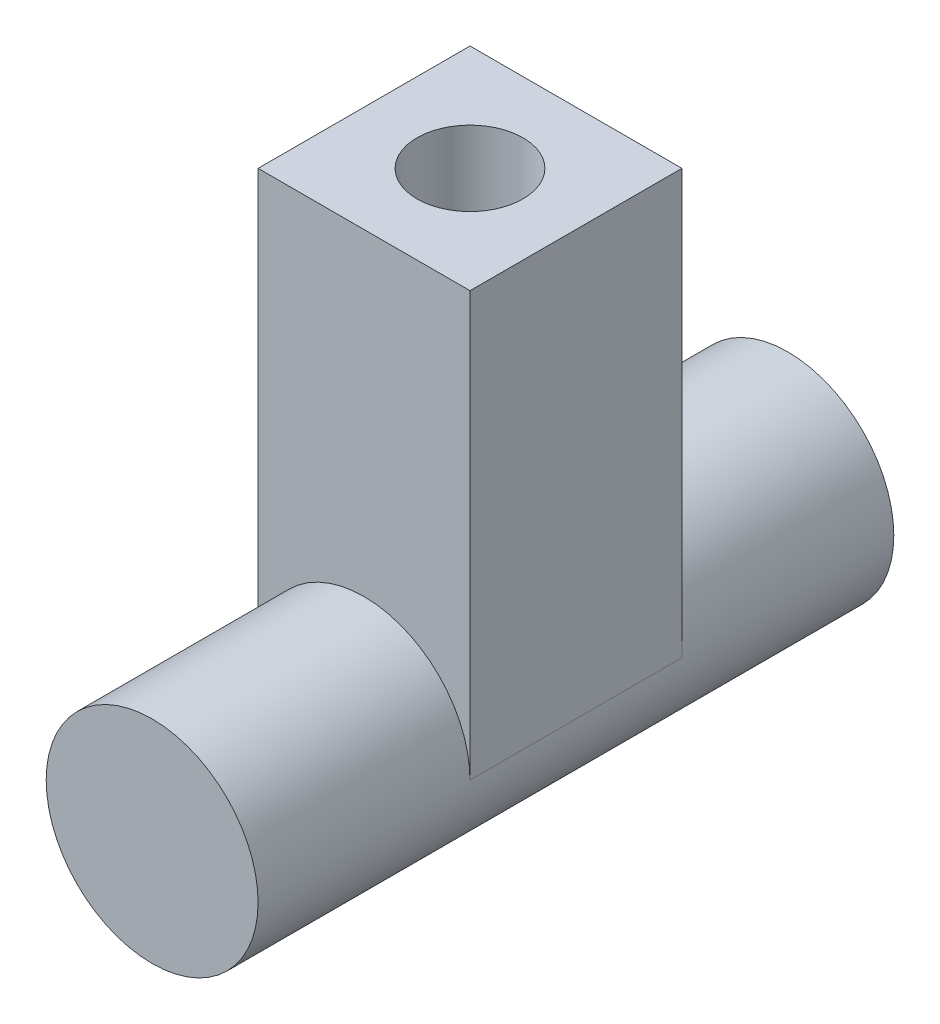
from build123d import *

# Parameters (mm, degrees)
SKETCH2_R           = 10
BOSS_EXTRUDE1_DEPTH = 30
SKETCH3_W           = 20
SKETCH3_H           = 20
BOSS_EXTRUDE2_DEPTH = 40
SKETCH4_R           = 5
CUT_EXTRUDE1_DEPTH  = 10


with BuildPart() as part:
    # Sketch2 → Boss-Extrude1 (new body, symmetric)
    with BuildSketch(Plane.XY):
        Circle(SKETCH2_R)
    extrude(amount=BOSS_EXTRUDE1_DEPTH, both=True)

    # Sketch3 → Boss-Extrude2 (add)
    with BuildSketch(Plane(origin=(0, 0, 0), x_dir=(1, 0, 0), z_dir=(0, 1, 0))):
        Rectangle(SKETCH3_W, SKETCH3_H)
    extrude(amount=BOSS_EXTRUDE2_DEPTH)

    # Sketch4 → Cut-Extrude1 (cut)
    with BuildSketch(Plane(origin=(0, 40, 0), x_dir=(1, 0, 0), z_dir=(0, 1, 0))):
        Circle(SKETCH4_R)
    extrude(amount=-CUT_EXTRUDE1_DEPTH, mode=Mode.SUBTRACT)


solid = part.part
